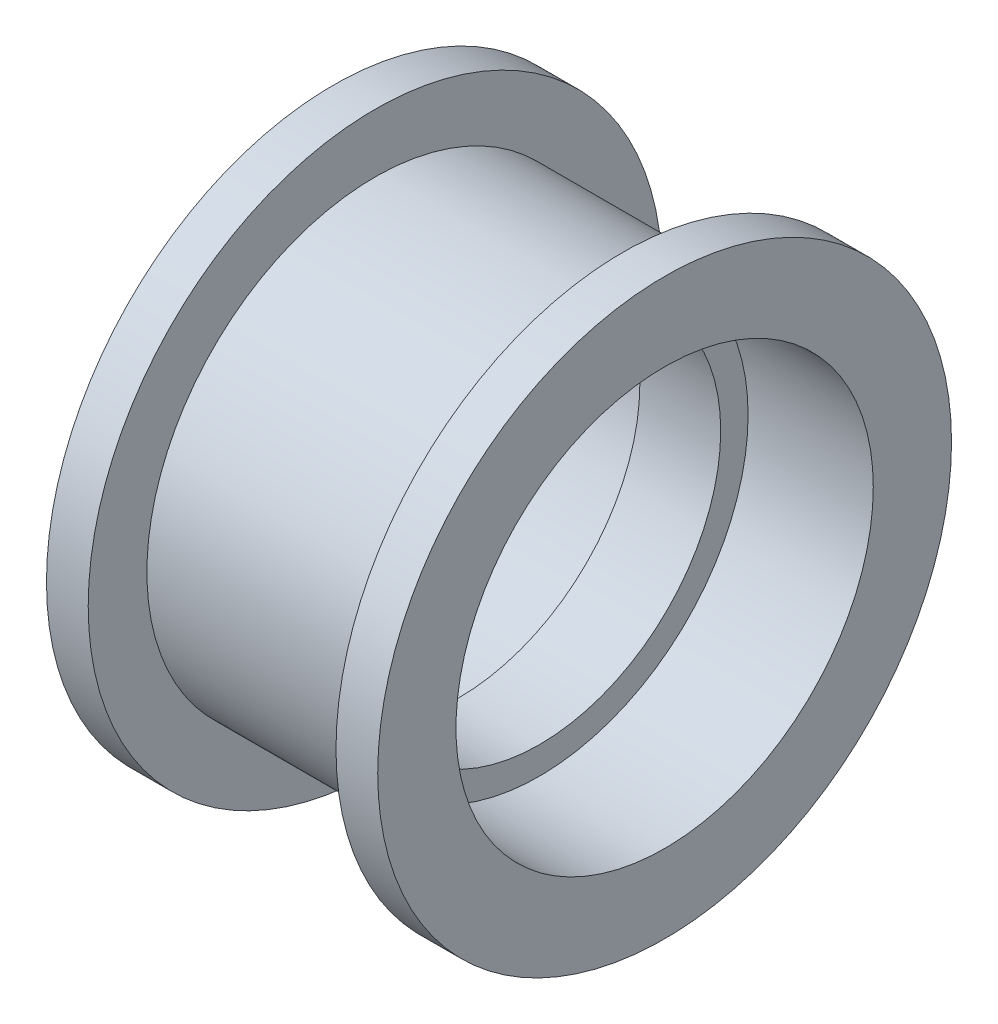
from build123d import *


with BuildPart() as part:
    # Sketch1 → Revolve1 (revolve)
    with BuildSketch(Plane.XY):
        Polygon((-1.55, 8), (-1.55, 6.95), (1.55, 6.95), (1.55, 8), (6.35, 8), (6.35, 11), (4.75, 11), (4.75, 8.75), (-4.75, 8.75), (-4.75, 11), (-6.35, 11), (-6.35, 8), align=None)
    revolve(axis=Axis((-6.35, 0, 0), (1, 0, 0)))


solid = part.part
